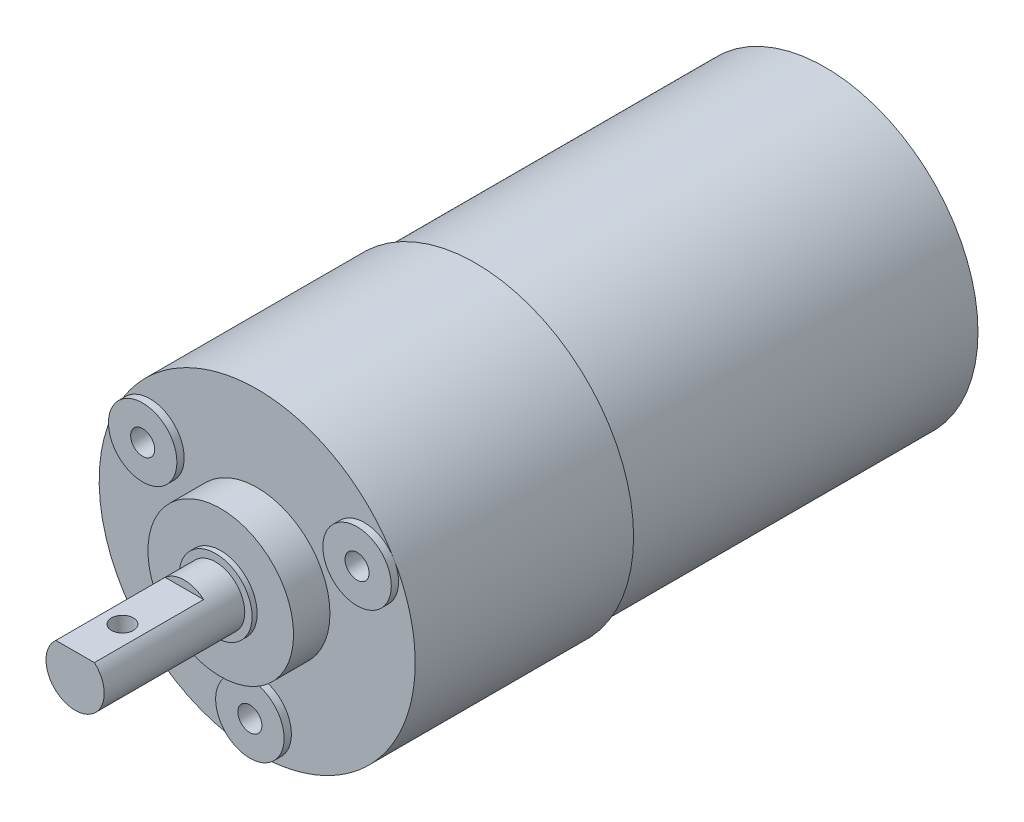
from build123d import *

# Parameters (mm, degrees)
SKETCH1_R                 = 21
BOSS_EXTRUDE1_DEPTH       = 48
SKETCH2_R                 = 21.7
BOSS_EXTRUDE2_DEPTH       = 30
SKETCH3_R                 = 4.7
BOSS_EXTRUDE3_DEPTH       = 1
SKETCH3_3_R               = 10
BOSS_EXTRUDE4_DEPTH       = 5
SKETCH4_R                 = 4
BOSS_EXTRUDE5_DEPTH       = 20
CUT_EXTRUDE1_DEPTH        = 108.474555128
CUT_EXTRUDE1_DEPTH_BACK   = 15
SKETCH6_R                 = 1.5
CUT_EXTRUDE2_DEPTH        = 15
M4X0_7_TAPPED_HOLE2_D     = 3.3
M4X0_7_TAPPED_HOLE2_DEPTH = 10.1
M4X0_7_TAPPED_HOLE2_TIP   = 0.991420021
SKETCH9_R                 = 5
SKETCH9_R_2               = 4
BOSS_EXTRUDE6_DEPTH       = 0.7


with BuildPart() as part:
    # Sketch1 → Boss-Extrude1 (new body)
    with BuildSketch(Plane.XY):
        Circle(SKETCH1_R)
    extrude(amount=BOSS_EXTRUDE1_DEPTH)

    # Sketch2 → Boss-Extrude2 (add)
    with BuildSketch(Plane.XY.offset(48)):
        Circle(SKETCH2_R)
    extrude(amount=BOSS_EXTRUDE2_DEPTH)

    # Sketch3 → Boss-Extrude3 (add)
    with BuildSketch(Plane.XY.offset(78)):
        with Locations((0, -17)):
            Circle(SKETCH3_R)
        with Locations((-14.722431864, 8.5)):
            Circle(SKETCH3_R)
        with Locations((14.722431864, 8.5)):
            Circle(SKETCH3_R)
    extrude(amount=BOSS_EXTRUDE3_DEPTH)

    # Sketch3_3 → Boss-Extrude4 (add)
    with BuildSketch(Plane.XY.offset(78)):
        Circle(SKETCH3_3_R)
    extrude(amount=BOSS_EXTRUDE4_DEPTH)

    # Sketch4 → Boss-Extrude5 (add)
    with BuildSketch(Plane.XY.offset(83)):
        Circle(SKETCH4_R)
    extrude(amount=BOSS_EXTRUDE5_DEPTH)

    # Sketch5 → Cut-Extrude1 (cut, two sides: drawn at the far end of the back side and taken through both)
    with BuildSketch(Plane.XY.offset(103).offset(-CUT_EXTRUDE1_DEPTH_BACK)):
        Polygon((-82.008727225, 3), (-2.645751311, 3), (2.645751311, 3), (82.008727225, 3), (82.008727225, 161.725951827), (-82.008727225, 161.725951827), align=None)
    extrude(amount=CUT_EXTRUDE1_DEPTH + CUT_EXTRUDE1_DEPTH_BACK, mode=Mode.SUBTRACT)

    # Sketch6 → Cut-Extrude2 (cut)
    with BuildSketch(Plane(origin=(0, 3, 0), x_dir=(1, 0, 0), z_dir=(0, 1, 0))):
        with Locations((0, -96.5)):
            Circle(SKETCH6_R)
    extrude(amount=-CUT_EXTRUDE2_DEPTH, mode=Mode.SUBTRACT)

    # M4x0.7 Tapped Hole2
    with Locations(Plane(origin=(0, -17, 79), x_dir=(1, 0, 0), z_dir=(0, 0, 1))):
        with Locations((0, 0), (14.722431864, 25.5), (-14.722431864, 25.5)):
            Hole(M4X0_7_TAPPED_HOLE2_D / 2, depth=M4X0_7_TAPPED_HOLE2_DEPTH)
            with Locations((0, 0, -(M4X0_7_TAPPED_HOLE2_DEPTH + M4X0_7_TAPPED_HOLE2_TIP / 2))):  # 118° drill point
                Cone(0, M4X0_7_TAPPED_HOLE2_D / 2, M4X0_7_TAPPED_HOLE2_TIP, mode=Mode.SUBTRACT)

    # Sketch9 → Boss-Extrude6 (add)
    with BuildSketch(Plane.XY.offset(83)):
        Circle(SKETCH9_R)
        Circle(SKETCH9_R_2, mode=Mode.SUBTRACT)
    extrude(amount=BOSS_EXTRUDE6_DEPTH)


solid = part.part
